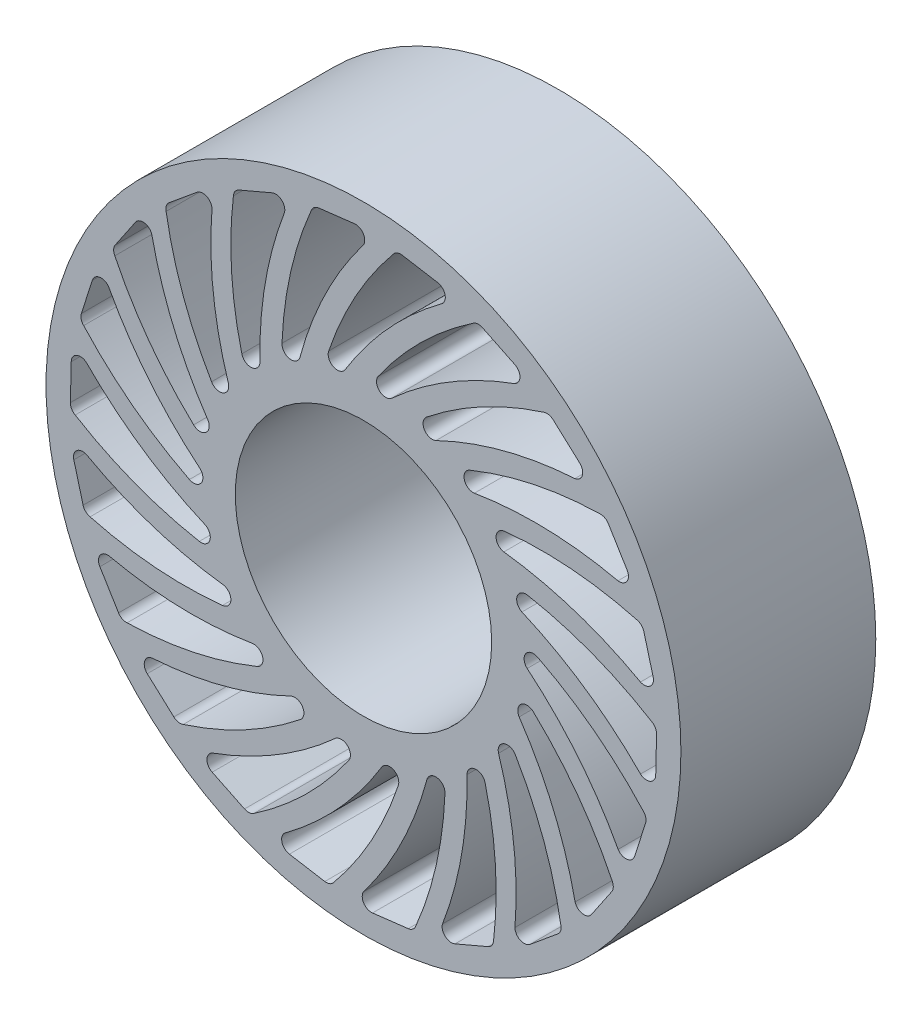
from build123d import *

# Parameters (mm, degrees)
SKETCH1_R          = 82.55
SKETCH1_R_2        = 33.3375
BASE_EXTRUDE_DEPTH = 25.3365
CUT_EXTRUDE2_DEPTH = 51.673


with BuildPart() as part:
    # Sketch1 → Base-Extrude (new body, symmetric)
    with BuildSketch(Plane.XY):
        Circle(SKETCH1_R)
        Circle(SKETCH1_R_2, mode=Mode.SUBTRACT)
        with BuildLine():
            Line((11.63374765, -75.330997168), (2.358698358, -76.436336376))
            ThreePointArc((2.358698358, -76.436336376), (0.040255798, -75.340756383), (0.051532593, -72.776512975))
            ThreePointArc((0.051532593, -72.776512975), (9.915637046, -56.812633), (16.526688502, -39.25017249))
            ThreePointArc((16.526688502, -39.25017249), (19.229545722, -37.60152759), (21.192738239, -40.085343666))
            ThreePointArc((21.192738239, -40.085343666), (18.93785378, -57.284870405), (13.591070982, -73.786995652))
            ThreePointArc((13.591070982, -73.786995652), (12.829928517, -74.834744481), (11.63374765, -75.330997168))
        make_face(mode=Mode.SUBTRACT)
    extrude(amount=BASE_EXTRUDE_DEPTH, both=True)

    # Sketch2 → Cut-Extrude2 (cut, through all)
    with BuildSketch(Plane.XY.offset(25.3365)):
        with BuildLine():
            Line((2.358698358, -76.436336376), (11.63374765, -75.330997168))
            ThreePointArc((11.63374765, -75.330997168), (12.829928517, -74.834744481), (13.591070982, -73.786995652))
            ThreePointArc((13.591070982, -73.786995652), (18.93785378, -57.284870405), (21.192738239, -40.085343666))
            ThreePointArc((21.192738239, -40.085343666), (19.229545722, -37.60152759), (16.526688502, -39.25017249))
            ThreePointArc((16.526688502, -39.25017249), (9.915637046, -56.812633), (0.051532593, -72.776512975))
            ThreePointArc((0.051532593, -72.776512975), (0.040255798, -75.340756383), (2.358698358, -76.436336376))
        make_face()
        with BuildLine():
            Line((-19.271449982, -74.0046498), (-10.060695314, -75.557167949))
            ThreePointArc((-10.060695314, -75.557167949), (-8.773157639, -75.418020077), (-7.747661835, -74.627151051))
            ThreePointArc((-7.747661835, -74.627151051), (2.031724629, -60.299840615), (9.040937069, -44.432289923))
            ThreePointArc((9.040937069, -44.432289923), (7.857039497, -41.495990603), (4.799190043, -42.316370925))
            ThreePointArc((4.799190043, -42.316370925), (-6.491984281, -57.304879954), (-20.454067918, -69.843071253))
            ThreePointArc((-20.454067918, -69.843071253), (-21.187318775, -72.300267745), (-19.271449982, -74.0046498))
        make_face()
        with BuildLine():
            Line((-39.340340055, -65.577546621), (-30.940080578, -69.662146339))
            ThreePointArc((-30.940080578, -69.662146339), (-29.665494739, -69.891376215), (-28.458725168, -69.421458496))
            ThreePointArc((-28.458725168, -69.421458496), (-15.039002767, -58.429676354), (-3.843307054, -45.1795963))
            ThreePointArc((-3.843307054, -45.1795963), (-4.15199734, -42.028695244), (-7.317110252, -41.954348653))
            ThreePointArc((-7.317110252, -41.954348653), (-22.373663652, -53.154626339), (-39.302601491, -61.25135927))
            ThreePointArc((-39.302601491, -61.25135927), (-40.698422786, -63.402441401), (-39.340340055, -65.577546621))
        make_face()
        with BuildLine():
            Line((-56.222109743, -51.837740619), (-49.312884521, -58.123511929))
            ThreePointArc((-49.312884521, -58.123511929), (-48.154509883, -58.702548712), (-46.864231839, -58.591652238))
            ThreePointArc((-46.864231839, -58.591652238), (-30.8913596, -51.825887211), (-16.416189296, -42.266720477))
            ThreePointArc((-16.416189296, -42.266720477), (-15.824664046, -39.15648495), (-18.84062179, -38.193434565))
            ThreePointArc((-18.84062179, -38.193434565), (-36.442761854, -44.698101021), (-54.967072032, -47.697426436))
            ThreePointArc((-54.967072032, -47.697426436), (-56.912382626, -49.368126323), (-56.222109743, -51.837740619))
        make_face()
        with BuildLine():
            Line((-68.549098466, -33.898349163), (-63.690651835, -41.876056257))
            ThreePointArc((-63.690651835, -41.876056257), (-62.742333022, -42.757989829), (-61.473077158, -43.015098775))
            ThreePointArc((-61.473077158, -43.015098775), (-44.241082196, -41.023472906), (-27.659129513, -35.929646332))
            ThreePointArc((-27.659129513, -35.929646332), (-26.215310584, -33.112049118), (-28.837778201, -31.338315554))
            ThreePointArc((-28.837778201, -31.338315554), (-47.559484225, -32.620401388), (-66.1784373, -30.279331779))
            ThreePointArc((-66.1784373, -30.279331779), (-68.515639697, -31.334299255), (-68.549098466, -33.898349163))
        make_face()
        with BuildLine():
            Line((-75.322646908, -13.212715059), (-72.90858132, -22.236051553))
            ThreePointArc((-72.90858132, -22.236051553), (-72.247145483, -23.349432902), (-71.10173936, -23.953717829))
            ThreePointArc((-71.10173936, -23.953717829), (-54.006655424, -26.897580802), (-36.661291551, -26.681765922))
            ThreePointArc((-36.661291551, -26.681765922), (-34.482148566, -24.385071991), (-36.498669327, -21.944352593))
            ThreePointArc((-36.498669327, -21.944352593), (-54.823220031, -17.899990836), (-72.028419155, -10.408185739))
            ThreePointArc((-72.028419155, -10.408185739), (-74.568167118, -10.761953612), (-75.322646908, -13.212715059))
        make_face()
        with BuildLine():
            Line((-75.994002459, 8.54333464), (-76.219891151, -0.794614195))
            ThreePointArc((-76.219891151, -0.794614195), (-75.898923887, -2.049243786), (-74.970161498, -2.951749124))
            ThreePointArc((-74.970161498, -2.951749124), (-59.39693062, -10.592606667), (-42.693373781, -15.27228752))
            ThreePointArc((-42.693373781, -15.27228752), (-39.955447946, -13.682561356), (-41.202655329, -10.772588692))
            ThreePointArc((-41.202655329, -10.772588692), (-57.645504596, -1.729429481), (-72.043086861, 10.306169609))
            ThreePointArc((-72.043086861, 10.306169609), (-74.579625113, 10.682261508), (-75.994002459, 8.54333464))
        make_face()
        with BuildLine():
            Line((-70.508775884, 29.607254176), (-73.356318697, 20.711198079))
            ThreePointArc((-73.356318697, 20.711198079), (-73.401822866, 19.416962874), (-72.764947015, 18.289352742))
            ThreePointArc((-72.764947015, 18.289352742), (-59.975219744, 6.570517463), (-45.266692775, -2.625539211))
            ThreePointArc((-45.266692775, -2.625539211), (-42.191794556, -1.871570972), (-42.568647239, 1.271906277))
            ThreePointArc((-42.568647239, 1.271906277), (-55.79769321, 14.581239965), (-66.221252125, 30.185580389))
            ThreePointArc((-66.221252125, 30.185580389), (-68.549085423, 31.26106333), (-70.508775884, 29.607254176))
        make_face()
        with BuildLine():
            Line((-59.311347619, 48.272570059), (-64.54985357, 40.539112259))
            ThreePointArc((-64.54985357, 40.539112259), (-64.958142694, 39.31012268), (-64.664749276, 38.048760019))
            ThreePointArc((-64.664749276, 38.048760019), (-55.694673251, 23.201337344), (-44.172773531, 10.23391467))
            ThreePointArc((-44.172773531, 10.23391467), (-41.010012896, 10.09104296), (-40.485980515, 13.213358963))
            ThreePointArc((-40.485980515, 13.213358963), (-49.429484561, 29.710624067), (-55.034565375, 47.619534966))
            ThreePointArc((-55.034565375, 47.619534966), (-56.96510651, 49.307279719), (-59.311347619, 48.272570059))
        make_face()
        with BuildLine():
            Line((-43.308866708, 63.027129405), (-50.5139432, 57.082788659))
            ThreePointArc((-50.5139432, 57.082788659), (-51.251940122, 56.018610132), (-51.325798126, 54.725683044))
            ThreePointArc((-51.325798126, 54.725683044), (-46.90207556, 37.952522858), (-39.500238882, 22.264277649))
            ThreePointArc((-39.500238882, 22.264277649), (-36.505843887, 21.236140606), (-35.123380428, 24.08434389))
            ThreePointArc((-35.123380428, 24.08434389), (-39.056793042, 42.433030102), (-39.389305442, 61.195638024))
            ThreePointArc((-39.389305442, 61.195638024), (-40.766153451, 63.358913546), (-43.308866708, 63.027129405))
        make_face()
        with BuildLine():
            Line((-23.797758984, 72.675605562), (-32.385693569, 69.001957007))
            ThreePointArc((-32.385693569, 69.001957007), (-33.393610168, 68.188802947), (-33.828736058, 66.969056695))
            ThreePointArc((-33.828736058, 66.969056695), (-34.309750645, 49.629020682), (-31.627629795, 32.490921262))
            ThreePointArc((-31.627629795, 32.490921262), (-29.044188515, 30.660812437), (-26.915292947, 33.004158509))
            ThreePointArc((-26.915292947, 33.004158509), (-25.519952431, 51.717764398), (-20.552958239, 69.814034434))
            ThreePointArc((-20.552958239, 69.814034434), (-21.264569086, 72.277585007), (-23.797758984, 72.675605562))
        make_face()
        with BuildLine():
            Line((-2.358698358, 76.436336376), (-11.63374765, 75.330997168))
            ThreePointArc((-11.63374765, 75.330997168), (-12.829928517, 74.834744481), (-13.591070982, 73.786995652))
            ThreePointArc((-13.591070982, 73.786995652), (-18.93785378, 57.284870405), (-21.192738239, 40.085343666))
            ThreePointArc((-21.192738239, 40.085343666), (-19.229545722, 37.60152759), (-16.526688502, 39.25017249))
            ThreePointArc((-16.526688502, 39.25017249), (-9.915637046, 56.812633), (-0.051532593, 72.776512975))
            ThreePointArc((-0.051532593, 72.776512975), (-0.040255798, 75.340756383), (-2.358698358, 76.436336376))
        make_face()
        with BuildLine():
            Line((19.271449982, 74.0046498), (10.060695314, 75.557167949))
            ThreePointArc((10.060695314, 75.557167949), (8.773157639, 75.418020077), (7.747661835, 74.627151051))
            ThreePointArc((7.747661835, 74.627151051), (-2.03172463, 60.299840615), (-9.040937069, 44.432289923))
            ThreePointArc((-9.040937069, 44.432289923), (-7.857039497, 41.495990603), (-4.799190043, 42.316370925))
            ThreePointArc((-4.799190043, 42.316370925), (6.491984281, 57.304879954), (20.454067918, 69.843071253))
            ThreePointArc((20.454067918, 69.843071253), (21.187318775, 72.300267745), (19.271449982, 74.0046498))
        make_face()
        with BuildLine():
            Line((39.340340055, 65.577546621), (30.940080578, 69.662146339))
            ThreePointArc((30.940080578, 69.662146339), (29.665494739, 69.891376215), (28.458725168, 69.421458496))
            ThreePointArc((28.458725168, 69.421458496), (15.039002767, 58.429676354), (3.843307054, 45.1795963))
            ThreePointArc((3.843307054, 45.1795963), (4.15199734, 42.028695244), (7.317110252, 41.954348653))
            ThreePointArc((7.317110252, 41.954348653), (22.373663652, 53.154626339), (39.302601491, 61.25135927))
            ThreePointArc((39.302601491, 61.25135927), (40.698422786, 63.402441401), (39.340340055, 65.577546621))
        make_face()
        with BuildLine():
            Line((56.222109743, 51.837740619), (49.312884521, 58.123511929))
            ThreePointArc((49.312884521, 58.123511929), (48.154509883, 58.702548712), (46.864231839, 58.591652238))
            ThreePointArc((46.864231839, 58.591652238), (30.8913596, 51.825887211), (16.416189296, 42.266720477))
            ThreePointArc((16.416189296, 42.266720477), (15.824664046, 39.15648495), (18.84062179, 38.193434565))
            ThreePointArc((18.84062179, 38.193434565), (36.442761854, 44.698101021), (54.967072032, 47.697426436))
            ThreePointArc((54.967072032, 47.697426436), (56.912382626, 49.368126323), (56.222109743, 51.837740619))
        make_face()
        with BuildLine():
            Line((68.549098466, 33.898349163), (63.690651835, 41.876056257))
            ThreePointArc((63.690651835, 41.876056257), (62.742333022, 42.757989829), (61.473077158, 43.015098775))
            ThreePointArc((61.473077158, 43.015098775), (44.241082196, 41.023472906), (27.659129513, 35.929646332))
            ThreePointArc((27.659129513, 35.929646332), (26.215310584, 33.112049118), (28.837778201, 31.338315554))
            ThreePointArc((28.837778201, 31.338315554), (47.559484225, 32.620401388), (66.1784373, 30.279331779))
            ThreePointArc((66.1784373, 30.279331779), (68.515639697, 31.334299254), (68.549098466, 33.898349163))
        make_face()
        with BuildLine():
            Line((75.322646908, 13.212715059), (72.90858132, 22.236051553))
            ThreePointArc((72.90858132, 22.236051553), (72.247145483, 23.349432902), (71.10173936, 23.953717829))
            ThreePointArc((71.10173936, 23.953717829), (54.006655424, 26.897580802), (36.661291551, 26.681765922))
            ThreePointArc((36.661291551, 26.681765922), (34.482148566, 24.385071991), (36.498669327, 21.944352593))
            ThreePointArc((36.498669327, 21.944352593), (54.823220031, 17.899990836), (72.028419155, 10.408185739))
            ThreePointArc((72.028419155, 10.408185739), (74.568167118, 10.761953612), (75.322646908, 13.212715059))
        make_face()
        with BuildLine():
            Line((75.994002459, -8.54333464), (76.219891151, 0.794614195))
            ThreePointArc((76.219891151, 0.794614195), (75.898923887, 2.049243786), (74.970161498, 2.951749123))
            ThreePointArc((74.970161498, 2.951749123), (59.39693062, 10.592606667), (42.693373781, 15.27228752))
            ThreePointArc((42.693373781, 15.27228752), (39.955447946, 13.682561356), (41.202655329, 10.772588692))
            ThreePointArc((41.202655329, 10.772588692), (57.645504596, 1.729429481), (72.043086861, -10.306169609))
            ThreePointArc((72.043086861, -10.306169609), (74.579625113, -10.682261508), (75.994002459, -8.54333464))
        make_face()
        with BuildLine():
            Line((70.508775884, -29.607254176), (73.356318697, -20.711198079))
            ThreePointArc((73.356318697, -20.711198079), (73.401822866, -19.416962874), (72.764947015, -18.289352742))
            ThreePointArc((72.764947015, -18.289352742), (59.975219744, -6.570517463), (45.266692775, 2.625539211))
            ThreePointArc((45.266692775, 2.625539211), (42.191794556, 1.871570972), (42.568647239, -1.271906277))
            ThreePointArc((42.568647239, -1.271906277), (55.79769321, -14.581239965), (66.221252125, -30.185580389))
            ThreePointArc((66.221252125, -30.185580389), (68.549085423, -31.26106333), (70.508775884, -29.607254176))
        make_face()
        with BuildLine():
            Line((59.311347619, -48.272570059), (64.54985357, -40.539112259))
            ThreePointArc((64.54985357, -40.539112259), (64.958142694, -39.31012268), (64.664749276, -38.048760019))
            ThreePointArc((64.664749276, -38.048760019), (55.694673251, -23.201337344), (44.172773531, -10.23391467))
            ThreePointArc((44.172773531, -10.23391467), (41.010012896, -10.09104296), (40.485980515, -13.213358963))
            ThreePointArc((40.485980515, -13.213358963), (49.429484561, -29.710624067), (55.034565375, -47.619534966))
            ThreePointArc((55.034565375, -47.619534966), (56.96510651, -49.307279719), (59.311347619, -48.272570059))
        make_face()
        with BuildLine():
            Line((43.308866708, -63.027129405), (50.5139432, -57.082788659))
            ThreePointArc((50.5139432, -57.082788659), (51.251940122, -56.018610132), (51.325798126, -54.725683044))
            ThreePointArc((51.325798126, -54.725683044), (46.90207556, -37.952522858), (39.500238882, -22.264277649))
            ThreePointArc((39.500238882, -22.264277649), (36.505843887, -21.236140606), (35.123380428, -24.08434389))
            ThreePointArc((35.123380428, -24.08434389), (39.056793042, -42.433030102), (39.389305442, -61.195638024))
            ThreePointArc((39.389305442, -61.195638024), (40.766153451, -63.358913546), (43.308866708, -63.027129405))
        make_face()
        with BuildLine():
            Line((23.797758984, -72.675605562), (32.385693569, -69.001957007))
            ThreePointArc((32.385693569, -69.001957007), (33.393610168, -68.188802947), (33.828736058, -66.969056695))
            ThreePointArc((33.828736058, -66.969056695), (34.309750645, -49.629020682), (31.627629795, -32.490921262))
            ThreePointArc((31.627629795, -32.490921262), (29.044188515, -30.660812437), (26.915292947, -33.004158509))
            ThreePointArc((26.915292947, -33.004158509), (25.519952431, -51.717764398), (20.552958239, -69.814034434))
            ThreePointArc((20.552958239, -69.814034434), (21.264569086, -72.277585007), (23.797758984, -72.675605562))
        make_face()
    extrude(amount=-CUT_EXTRUDE2_DEPTH, mode=Mode.SUBTRACT)


solid = part.part
